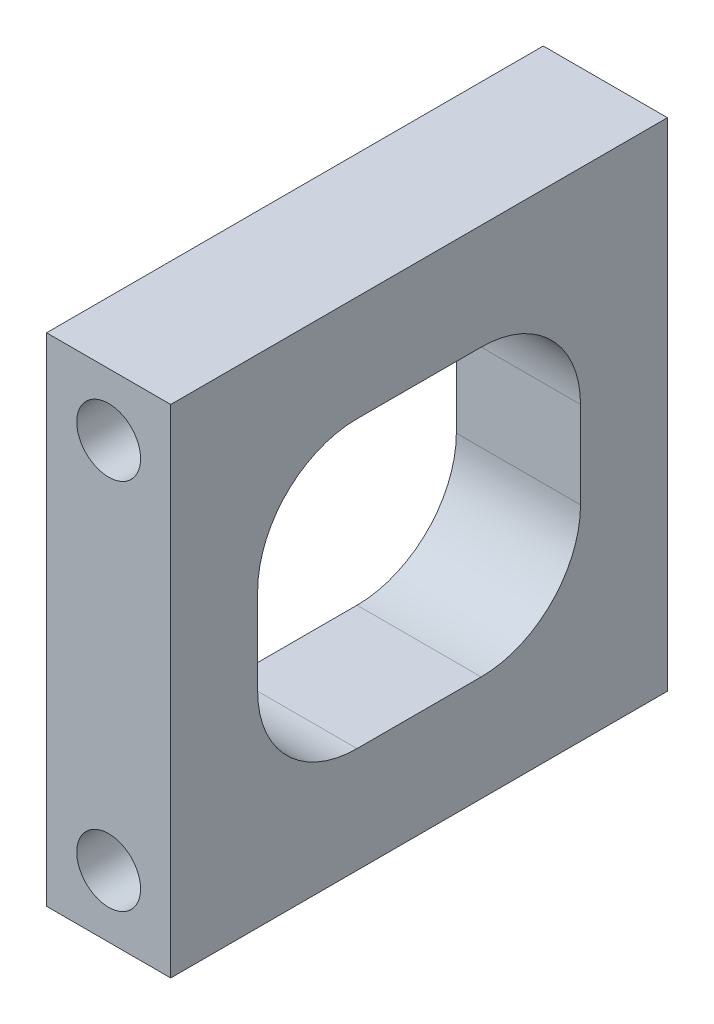
from build123d import *

# Parameters (mm, degrees)
SKETCH1_W           = 12.7
SKETCH1_H           = 50.8
BOSS_EXTRUDE1_DEPTH = 50.8
SKETCH2_R           = 3.2639
CUT_EXTRUDE1_DEPTH  = 19.05
SKETCH3_W           = 33.02
SKETCH3_H           = 29.21
CUT_EXTRUDE2_DEPTH  = 13.7
FILLET1_R           = 10.16


with BuildPart() as part:
    # Sketch1 → Boss-Extrude1 (new body)
    with BuildSketch(Plane.XY):
        with Locations((6.35, 25.4)):
            Rectangle(SKETCH1_W, SKETCH1_H)
    extrude(amount=BOSS_EXTRUDE1_DEPTH)

    # Sketch2 → Cut-Extrude1 (cut)
    with BuildSketch(Plane.XY.offset(50.8)):
        with Locations((6.35, 44.45)):
            Circle(SKETCH2_R)
        with Locations((6.35, 6.35)):
            Circle(SKETCH2_R)
    cut_extrude1 = extrude(amount=-CUT_EXTRUDE1_DEPTH, mode=Mode.SUBTRACT)

    # Mirror1: Cut-Extrude1 across plane
    add(cut_extrude1.mirror(Plane.XY.offset(25.4)), mode=Mode.SUBTRACT)

    # Sketch3 → Cut-Extrude2 (cut, through all)
    with BuildSketch(Plane.ZY):
        with Locations((25.4, 25.4)):
            Rectangle(SKETCH3_W, SKETCH3_H)
    extrude(amount=-CUT_EXTRUDE2_DEPTH, mode=Mode.SUBTRACT)

    # Fillet1
    fillet1_edges = [part.edges().sort_by_distance(p)[0] for p in [
        (6.35, 10.795, 8.89),
        (6.35, 40.005, 8.89),
        (6.35, 40.005, 41.91),
        (6.35, 10.795, 41.91),
    ]]
    fillet(fillet1_edges, radius=FILLET1_R)


solid = part.part
